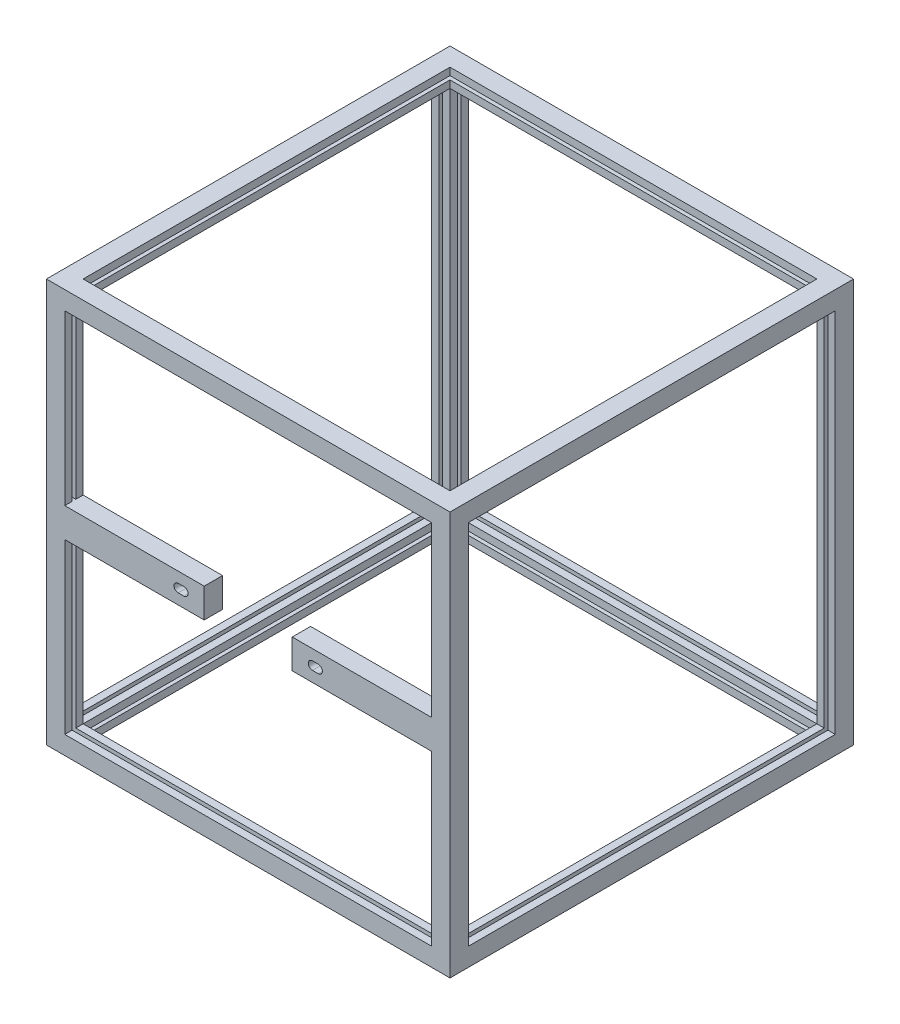
from build123d import *

# Parameters (mm, degrees)
CROQUIS2_W                   = 220
CROQUIS2_H                   = 220
CROQUIS2_W_2                 = 200
CROQUIS2_H_2                 = 200
SALIENTE_EXTRUIR1_DEPTH      = 10
CROQUIS3_W                   = 212
CROQUIS3_H                   = 212
CROQUIS3_W_2                 = 210
CROQUIS3_H_2                 = 210
CROQUIS3_W_3                 = 208
CROQUIS3_H_3                 = 208
CORTAR_EXTRUIR1_DEPTH        = 3.5
CROQUIS4_W                   = 10
CROQUIS4_H                   = 10
SALIENTE_EXTRUIR2_DEPTH      = 200
SALIENTE_EXTRUIR2_DEPTH_BACK = 10
CROQUIS6_W                   = 3.5
CROQUIS6_H                   = 2
CROQUIS6_W_2                 = 2
CROQUIS6_H_2                 = 3.5
CROQUIS6_W_3                 = 1.99805467
CORTAR_EXTRUIR2_DEPTH        = 203.5
CROQUIS7_W                   = 220
CROQUIS7_H                   = 220
CROQUIS7_W_2                 = 200
CROQUIS7_H_2                 = 200
SALIENTE_EXTRUIR3_DEPTH      = 10
CORTAR_EXTRUIR3_START        = -3.5
CROQUIS8_W                   = 207
CROQUIS8_H                   = 2
CORTAR_EXTRUIR3_DEPTH        = 207
MATRIZC1_COUNT               = 4
CROQUIS9_W                   = 86
CROQUIS9_H                   = 16
BRAZOS_DEPTH                 = 10
MATRIZC2_COUNT               = 4


with BuildPart() as part:
    # Croquis2 → Saliente-Extruir1 (new body)
    with BuildSketch(Plane.XY):
        with Locations((110, -110)):
            Rectangle(CROQUIS2_W, CROQUIS2_H)
        with Locations((110, -110)):
            Rectangle(CROQUIS2_W_2, CROQUIS2_H_2, mode=Mode.SUBTRACT)
    extrude(amount=SALIENTE_EXTRUIR1_DEPTH)

    # Croquis3 → Cortar-Extruir1 (cut)
    with BuildSketch(Plane.XY.offset(10)):
        with Locations((110, -110)):
            Rectangle(CROQUIS3_W, CROQUIS3_H)
        with Locations((110, -110)):
            Rectangle(CROQUIS3_W_2, CROQUIS3_H_2, mode=Mode.SUBTRACT)
        with Locations((110, -110)):
            Rectangle(CROQUIS3_W_2, CROQUIS3_H_2)
        with Locations((110, -110)):
            Rectangle(CROQUIS3_W_3, CROQUIS3_H_3, mode=Mode.SUBTRACT)
    extrude(amount=-CORTAR_EXTRUIR1_DEPTH, mode=Mode.SUBTRACT)

    # Croquis4 → Saliente-Extruir2 (add, two sides)
    with BuildSketch(Plane.XY.offset(10)) as saliente_extruir2_sk:
        with Locations((5, -5)):
            Rectangle(CROQUIS4_W, CROQUIS4_H)
        with Locations((215, -5)):
            Rectangle(CROQUIS4_W, CROQUIS4_H)
        with Locations((215, -215)):
            Rectangle(CROQUIS4_W, CROQUIS4_H)
        with Locations((5, -215)):
            Rectangle(CROQUIS4_W, CROQUIS4_H)
    extrude(amount=SALIENTE_EXTRUIR2_DEPTH)
    extrude(saliente_extruir2_sk.sketch, amount=-SALIENTE_EXTRUIR2_DEPTH_BACK)

    # Croquis6 → Cortar-Extruir2 (cut)
    with BuildSketch(Plane.XY.offset(210)):
        with Locations((8.25, -5)):
            Rectangle(CROQUIS6_W, CROQUIS6_H)
        with Locations((5, -8.25)):
            Rectangle(CROQUIS6_W_2, CROQUIS6_H_2)
        with Locations((211.75, -5)):
            Rectangle(CROQUIS6_W, CROQUIS6_H)
        with Locations((215, -8.25)):
            Rectangle(CROQUIS6_W_2, CROQUIS6_H_2)
        with Locations((211.75, -215)):
            Rectangle(CROQUIS6_W, CROQUIS6_H)
        with Locations((215.000972665, -211.75)):
            Rectangle(CROQUIS6_W_3, CROQUIS6_H_2)
        with Locations((5, -211.75)):
            Rectangle(CROQUIS6_W_2, CROQUIS6_H_2)
        with Locations((8.25, -215)):
            Rectangle(CROQUIS6_W, CROQUIS6_H)
    extrude(amount=-CORTAR_EXTRUIR2_DEPTH, mode=Mode.SUBTRACT)

    # Croquis7 → Saliente-Extruir3 (add)
    with BuildSketch(Plane.XY.offset(210)):
        with Locations((110, -110)):
            Rectangle(CROQUIS7_W, CROQUIS7_H)
        with Locations((110, -110)):
            Rectangle(CROQUIS7_W_2, CROQUIS7_H_2, mode=Mode.SUBTRACT)
    extrude(amount=SALIENTE_EXTRUIR3_DEPTH)

    # Croquis8 → Cortar-Extruir3 (cut)
    with BuildSketch(Plane(origin=(0, -210, 0), x_dir=(1, 0, 0), z_dir=(0, 1, 0)).offset(CORTAR_EXTRUIR3_START)):
        with Locations((110, -215)):
            Rectangle(CROQUIS8_W, CROQUIS8_H)
    cortar_extruir3 = extrude(amount=CORTAR_EXTRUIR3_DEPTH, mode=Mode.SUBTRACT)

    # MatrizC1: Cortar-Extruir3 ×4 about axis
    matrizc1_axis = Axis((0, -110, 110), (1, 0, 0))
    for i in range(1, MATRIZC1_COUNT):
        add(cortar_extruir3.rotate(matrizc1_axis, i * 360 / MATRIZC1_COUNT), mode=Mode.SUBTRACT)

    # Croquis9 → Brazos (add)
    with BuildSketch(Plane.XY.offset(220)):
        with Locations((43, -110)):
            Rectangle(CROQUIS9_W, CROQUIS9_H)
        with BuildLine():
            ThreePointArc((71.801526277, -112.25), (69.551526277, -110), (71.801526277, -107.75))
            Line((71.801526277, -107.75), (75, -107.75))
            ThreePointArc((75, -107.75), (77.25, -110), (75, -112.25))
            Line((75, -112.25), (71.801526277, -112.25))
        make_face(mode=Mode.SUBTRACT)
        with Locations((177, -110)):
            Rectangle(CROQUIS9_W, CROQUIS9_H)
        with BuildLine():
            Line((145, -107.75), (148.198473723, -107.75))
            ThreePointArc((148.198473723, -107.75), (150.448473723, -110), (148.198473723, -112.25))
            Line((148.198473723, -112.25), (145, -112.25))
            ThreePointArc((145, -112.25), (142.75, -110), (145, -107.75))
        make_face(mode=Mode.SUBTRACT)
    extrude(amount=-BRAZOS_DEPTH)

    # MatrizC2: Cortar-Extruir3 ×4 about axis
    matrizc2_axis = Axis((110, 11, 110), (0, -1, 0))
    for i in range(1, MATRIZC2_COUNT):
        add(cortar_extruir3.rotate(matrizc2_axis, i * 360 / MATRIZC2_COUNT), mode=Mode.SUBTRACT)


solid = part.part
